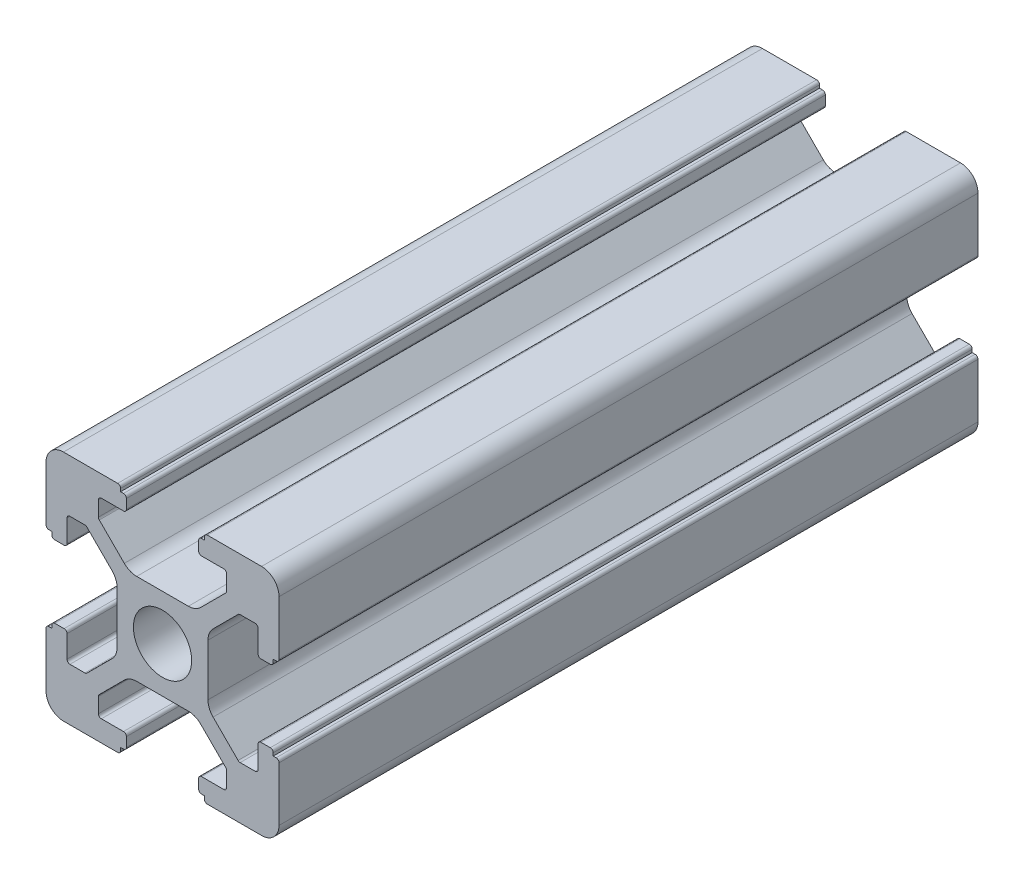
from build123d import *

# Parameters (mm, degrees)
SKETCH_1_R      = 2.5
EXTRUDE_1_DEPTH = 60


with BuildPart() as part:
    # 草图1 → 凸台-拉伸1 (new body)
    with BuildSketch(Plane.XY):
        with BuildLine():
            Line((-8.502261885, -10.002261885), (-3.85, -10.002261885))
            ThreePointArc((-3.85, -10.002261885), (-3.673223305, -9.929038581), (-3.6, -9.752261885))
            Line((-3.6, -9.752261885), (-3.6, -9.502261885))
            Line((-3.6, -9.502261885), (-3.35, -9.502261885))
            ThreePointArc((-3.35, -9.502261885), (-3.173223305, -9.429038581), (-3.1, -9.252261885))
            Line((-3.1, -9.252261885), (-3.1, -8.45))
            ThreePointArc((-3.1, -8.45), (-3.173223305, -8.273223305), (-3.35, -8.2))
            Line((-3.35, -8.2), (-5.25, -8.2))
            ThreePointArc((-5.25, -8.2), (-5.426776695, -8.126776695), (-5.5, -7.95))
            Line((-5.5, -7.95), (-5.5, -6.664213562))
            ThreePointArc((-5.5, -6.664213562), (-5.480969883, -6.568542704), (-5.426776695, -6.487436867))
            Line((-5.426776695, -6.487436867), (-3.278679656, -4.339339828))
            ThreePointArc((-3.278679656, -4.339339828), (-2.792044633, -4.014180701), (-2.218019485, -3.9))
            Line((-2.218019485, -3.9), (2.218019485, -3.9))
            ThreePointArc((2.218019485, -3.9), (2.792044633, -4.014180701), (3.278679656, -4.339339828))
            Line((3.278679656, -4.339339828), (5.426776695, -6.487436867))
            ThreePointArc((5.426776695, -6.487436867), (5.480969883, -6.568542704), (5.5, -6.664213562))
            Line((5.5, -6.664213562), (5.5, -7.95))
            ThreePointArc((5.5, -7.95), (5.426776695, -8.126776695), (5.25, -8.2))
            Line((5.25, -8.2), (3.35, -8.2))
            ThreePointArc((3.35, -8.2), (3.173223305, -8.273223305), (3.1, -8.45))
            Line((3.1, -8.45), (3.1, -9.252261885))
            ThreePointArc((3.1, -9.252261885), (3.173223305, -9.429038581), (3.35, -9.502261885))
            Line((3.35, -9.502261885), (3.6, -9.502261885))
            Line((3.6, -9.502261885), (3.6, -9.752261885))
            ThreePointArc((3.6, -9.752261885), (3.673223305, -9.929038581), (3.85, -10.002261885))
            Line((3.85, -10.002261885), (8.502261885, -10.002261885))
            ThreePointArc((8.502261885, -10.002261885), (9.562922057, -9.562922057), (10.002261885, -8.502261885))
            Line((10.002261885, -8.502261885), (10.002261885, -3.85))
            ThreePointArc((10.002261885, -3.85), (9.929038581, -3.673223305), (9.752261885, -3.6))
            Line((9.752261885, -3.6), (9.502261885, -3.6))
            Line((9.502261885, -3.6), (9.502261885, -3.35))
            ThreePointArc((9.502261885, -3.35), (9.429038581, -3.173223305), (9.252261885, -3.1))
            Line((9.252261885, -3.1), (8.45, -3.1))
            ThreePointArc((8.45, -3.1), (8.273223305, -3.173223305), (8.2, -3.35))
            Line((8.2, -3.35), (8.2, -5.25))
            ThreePointArc((8.2, -5.25), (8.126776695, -5.426776695), (7.95, -5.5))
            Line((7.95, -5.5), (6.664213562, -5.5))
            ThreePointArc((6.664213562, -5.5), (6.568542704, -5.480969883), (6.487436867, -5.426776695))
            Line((6.487436867, -5.426776695), (4.339339828, -3.278679656))
            ThreePointArc((4.339339828, -3.278679656), (4.014180701, -2.792044633), (3.9, -2.218019485))
            Line((3.9, -2.218019485), (3.9, 2.218019485))
            ThreePointArc((3.9, 2.218019485), (4.014180701, 2.792044633), (4.339339828, 3.278679656))
            Line((4.339339828, 3.278679656), (6.487436867, 5.426776695))
            ThreePointArc((6.487436867, 5.426776695), (6.568542704, 5.480969883), (6.664213562, 5.5))
            Line((6.664213562, 5.5), (7.95, 5.5))
            ThreePointArc((7.95, 5.5), (8.126776695, 5.426776695), (8.2, 5.25))
            Line((8.2, 5.25), (8.2, 3.35))
            ThreePointArc((8.2, 3.35), (8.273223305, 3.173223305), (8.45, 3.1))
            Line((8.45, 3.1), (9.252261885, 3.1))
            ThreePointArc((9.252261885, 3.1), (9.429038581, 3.173223305), (9.502261885, 3.35))
            Line((9.502261885, 3.35), (9.502261885, 3.6))
            Line((9.502261885, 3.6), (9.752261885, 3.6))
            ThreePointArc((9.752261885, 3.6), (9.929038581, 3.673223305), (10.002261885, 3.85))
            Line((10.002261885, 3.85), (10.002261885, 8.502261885))
            ThreePointArc((10.002261885, 8.502261885), (9.562922057, 9.562922057), (8.502261885, 10.002261885))
            Line((8.502261885, 10.002261885), (3.85, 10.002261885))
            ThreePointArc((3.85, 10.002261885), (3.673223305, 9.929038581), (3.6, 9.752261885))
            Line((3.6, 9.752261885), (3.6, 9.502261885))
            Line((3.6, 9.502261885), (3.35, 9.502261885))
            ThreePointArc((3.35, 9.502261885), (3.173223305, 9.429038581), (3.1, 9.252261885))
            Line((3.1, 9.252261885), (3.1, 8.45))
            ThreePointArc((3.1, 8.45), (3.173223305, 8.273223305), (3.35, 8.2))
            Line((3.35, 8.2), (5.25, 8.2))
            ThreePointArc((5.25, 8.2), (5.426776695, 8.126776695), (5.5, 7.95))
            Line((5.5, 7.95), (5.5, 6.664213562))
            ThreePointArc((5.5, 6.664213562), (5.480969883, 6.568542704), (5.426776695, 6.487436867))
            Line((5.426776695, 6.487436867), (3.278679656, 4.339339828))
            ThreePointArc((3.278679656, 4.339339828), (2.792044633, 4.014180701), (2.218019485, 3.9))
            Line((2.218019485, 3.9), (-2.218019485, 3.9))
            ThreePointArc((-2.218019485, 3.9), (-2.792044633, 4.014180701), (-3.278679656, 4.339339828))
            Line((-3.278679656, 4.339339828), (-5.426776695, 6.487436867))
            ThreePointArc((-5.426776695, 6.487436867), (-5.480969883, 6.568542704), (-5.5, 6.664213562))
            Line((-5.5, 6.664213562), (-5.5, 7.95))
            ThreePointArc((-5.5, 7.95), (-5.426776695, 8.126776695), (-5.25, 8.2))
            Line((-5.25, 8.2), (-3.35, 8.2))
            ThreePointArc((-3.35, 8.2), (-3.173223305, 8.273223305), (-3.1, 8.45))
            Line((-3.1, 8.45), (-3.1, 9.252261885))
            ThreePointArc((-3.1, 9.252261885), (-3.173223305, 9.429038581), (-3.35, 9.502261885))
            Line((-3.35, 9.502261885), (-3.6, 9.502261885))
            Line((-3.6, 9.502261885), (-3.6, 9.752261885))
            ThreePointArc((-3.6, 9.752261885), (-3.673223305, 9.929038581), (-3.85, 10.002261885))
            Line((-3.85, 10.002261885), (-8.502261885, 10.002261885))
            ThreePointArc((-8.502261885, 10.002261885), (-9.562922057, 9.562922057), (-10.002261885, 8.502261885))
            Line((-10.002261885, 8.502261885), (-10.002261885, 3.85))
            ThreePointArc((-10.002261885, 3.85), (-9.929038581, 3.673223305), (-9.752261885, 3.6))
            Line((-9.752261885, 3.6), (-9.502261885, 3.6))
            Line((-9.502261885, 3.6), (-9.502261885, 3.35))
            ThreePointArc((-9.502261885, 3.35), (-9.429038581, 3.173223305), (-9.252261885, 3.1))
            Line((-9.252261885, 3.1), (-8.45, 3.1))
            ThreePointArc((-8.45, 3.1), (-8.273223305, 3.173223305), (-8.2, 3.35))
            Line((-8.2, 3.35), (-8.2, 5.25))
            ThreePointArc((-8.2, 5.25), (-8.126776695, 5.426776695), (-7.95, 5.5))
            Line((-7.95, 5.5), (-6.664213562, 5.5))
            ThreePointArc((-6.664213562, 5.5), (-6.568542704, 5.480969883), (-6.487436867, 5.426776695))
            Line((-6.487436867, 5.426776695), (-4.339339828, 3.278679656))
            ThreePointArc((-4.339339828, 3.278679656), (-4.014180701, 2.792044633), (-3.9, 2.218019485))
            Line((-3.9, 2.218019485), (-3.9, -2.218019485))
            ThreePointArc((-3.9, -2.218019485), (-4.014180701, -2.792044633), (-4.339339828, -3.278679656))
            Line((-4.339339828, -3.278679656), (-6.487436867, -5.426776695))
            ThreePointArc((-6.487436867, -5.426776695), (-6.568542704, -5.480969883), (-6.664213562, -5.5))
            Line((-6.664213562, -5.5), (-7.95, -5.5))
            ThreePointArc((-7.95, -5.5), (-8.126776695, -5.426776695), (-8.2, -5.25))
            Line((-8.2, -5.25), (-8.2, -3.35))
            ThreePointArc((-8.2, -3.35), (-8.273223305, -3.173223305), (-8.45, -3.1))
            Line((-8.45, -3.1), (-9.252261885, -3.1))
            ThreePointArc((-9.252261885, -3.1), (-9.429038581, -3.173223305), (-9.502261885, -3.35))
            Line((-9.502261885, -3.35), (-9.502261885, -3.6))
            Line((-9.502261885, -3.6), (-9.752261885, -3.6))
            ThreePointArc((-9.752261885, -3.6), (-9.929038581, -3.673223305), (-10.002261885, -3.85))
            Line((-10.002261885, -3.85), (-10.002261885, -8.502261885))
            ThreePointArc((-10.002261885, -8.502261885), (-9.562922057, -9.562922057), (-8.502261885, -10.002261885))
        make_face()
        Circle(SKETCH_1_R, mode=Mode.SUBTRACT)
    extrude(amount=EXTRUDE_1_DEPTH)


solid = part.part
